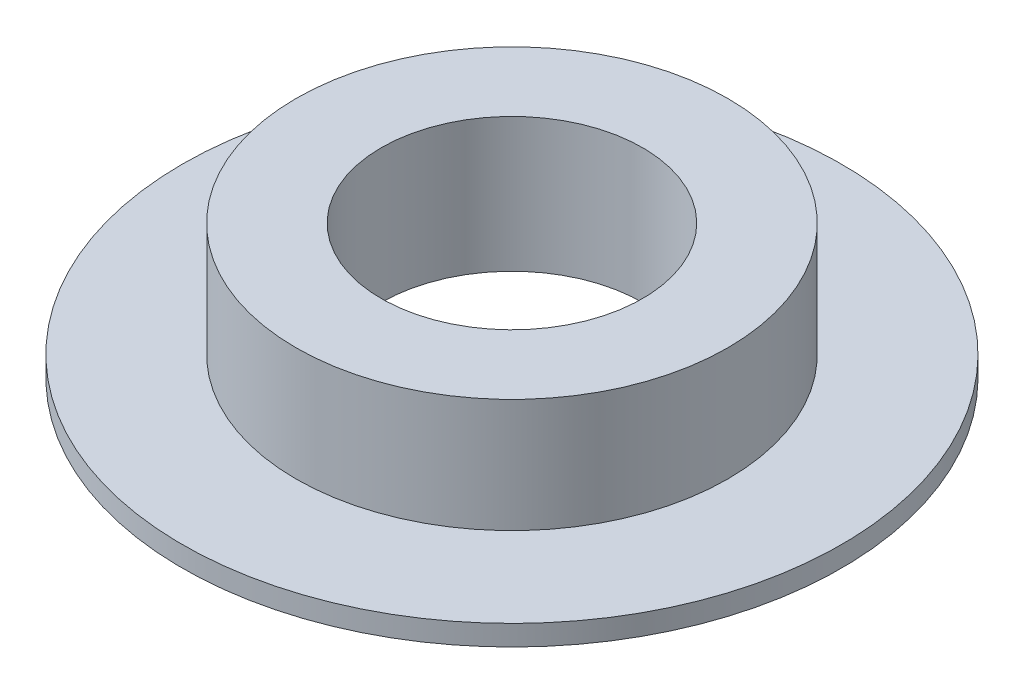
from build123d import *


with BuildPart() as part:
    # Croquis1 → Revolución1 (revolve)
    with BuildSketch(Plane.XY):
        Polygon((-48.52158728, 8.972889318), (-48.52158728, -2.827110682), (-66.02158728, -2.827110682), (-66.02158728, -1.027110682), (-56.02158728, -1.027110682), (-56.02158728, 8.972889318), align=None)
    revolve(axis=Axis((-37.02158728, 13.972889318, 0), (0, -1, 0)))


solid = part.part
